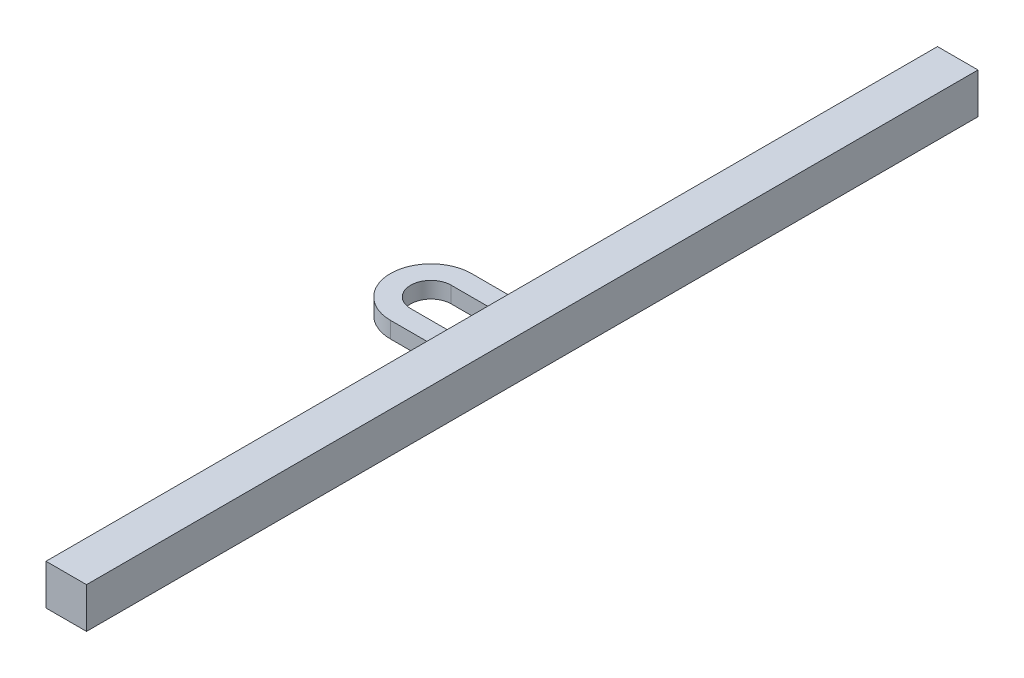
from build123d import *

# Parameters (mm, degrees)
BOSS_EXTRUDE1_DEPTH = 12.7
BOSS_EXTRUDE2_DEPTH = 5.08


with BuildPart() as part:
    # Sketch1 → Boss-Extrude1 (new body)
    with BuildSketch(Plane(origin=(0, 0, 0), x_dir=(1, 0, 0), z_dir=(0, 1, 0))):
        Polygon((-6.35, -12.7), (-6.35, -139.7), (6.35, -139.7), (6.35, 139.7), (-6.35, 139.7), (-6.35, 12.7), (-6.35, 6.35), (-6.35, -6.35), align=None)
    extrude(amount=BOSS_EXTRUDE1_DEPTH)

    # Sketch1_4 → Boss-Extrude2 (add)
    with BuildSketch(Plane(origin=(0, 0, 0), x_dir=(1, 0, 0), z_dir=(0, 1, 0))):
        with BuildLine():
            Line((-25.4, -12.7), (-6.35, -12.7))
            Line((-6.35, -12.7), (-6.35, -6.35))
            Line((-6.35, -6.35), (-25.4, -6.35))
            ThreePointArc((-25.4, -6.35), (-31.75, 0), (-25.4, 6.35))
            Line((-25.4, 6.35), (-6.35, 6.35))
            Line((-6.35, 6.35), (-6.35, 12.7))
            Line((-6.35, 12.7), (-25.4, 12.7))
            ThreePointArc((-25.4, 12.7), (-38.1, 0), (-25.4, -12.7))
        make_face()
    extrude(amount=BOSS_EXTRUDE2_DEPTH)


solid = part.part
